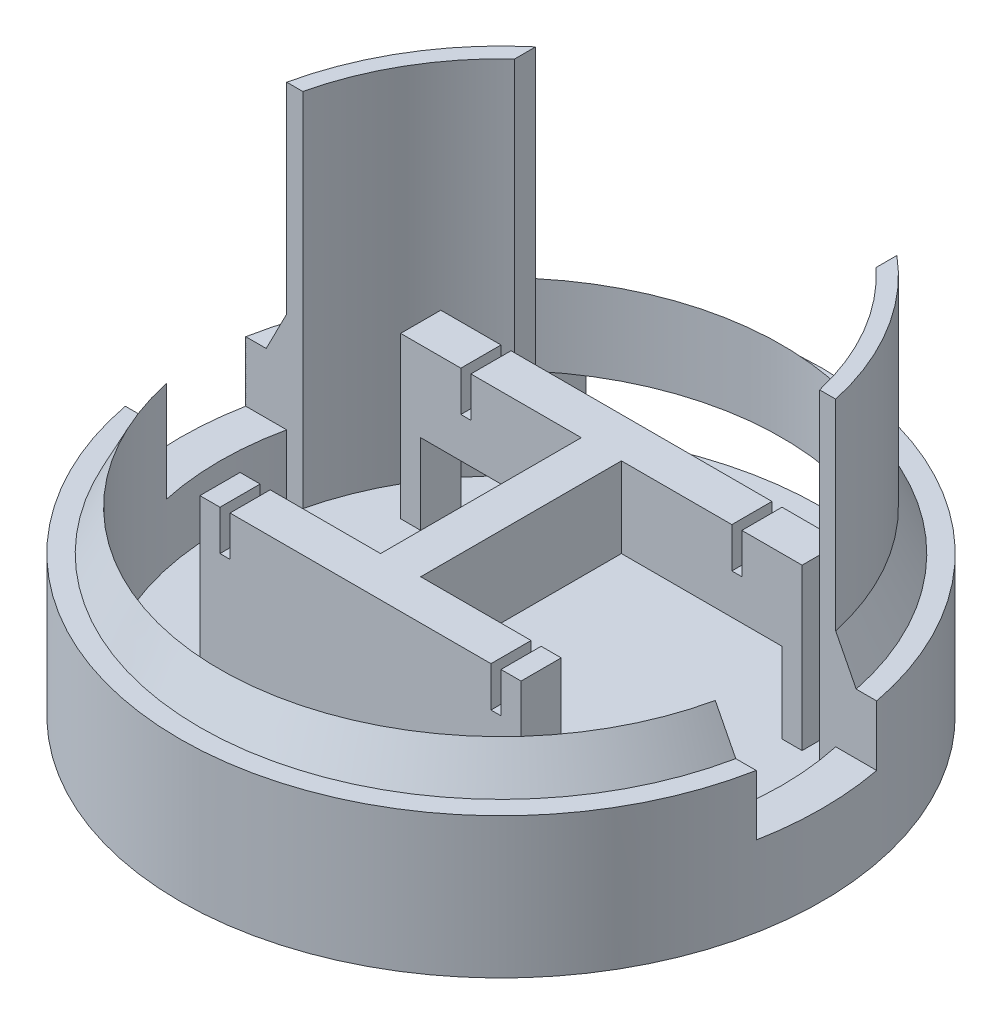
from build123d import *

# Parameters (mm, degrees)
SKETCH1_R               = 50.8
BOSS_EXTRUDE1_DEPTH     = 3.175
SKETCH2_R               = 50.8
SKETCH2_R_2             = 44.45
BOSS_EXTRUDE2_DEPTH     = 19.05
SKETCH5_W               = 50.8
SKETCH5_H               = 6.35
BOSS_EXTRUDE3_DEPTH     = 25.4
SKETCH6_W               = 1.5875
SKETCH6_H               = 6.35
CUT_EXTRUDE1_DEPTH      = 6.35
SKETCH7_W               = 19.05
SKETCH7_H               = 25.4
CUT_EXTRUDE2_DEPTH      = 51.8
CUT_EXTRUDE2_DEPTH_BACK = 51.8
SKETCH8_W               = 57.15
SKETCH8_H               = 12.7
CUT_EXTRUDE3_DEPTH      = 51.8
BOSS_EXTRUDE4_DEPTH     = 57.15
SKETCH10_W              = 6.35
SKETCH10_H              = 3.175
BOSS_EXTRUDE5_DEPTH     = 3.175
SKETCH11_W              = 3.175
SKETCH11_H              = 6.35
BOSS_EXTRUDE6_DEPTH     = 12.7
SKETCH12_W              = 63.5
SKETCH12_H              = 6.35
BOSS_EXTRUDE7_DEPTH     = 12.7
SKETCH14_W              = 6.35
SKETCH14_H              = 12.7
BOSS_EXTRUDE8_DEPTH     = 31.75
BOSS_EXTRUDE9_DEPTH     = 9.525


with BuildPart() as part:
    # Sketch1 → Boss-Extrude1 (new body)
    with BuildSketch(Plane(origin=(0, 0, 0), x_dir=(1, 0, 0), z_dir=(0, 1, 0))):
        with Locations(Location((0, 0, 0), (0, 0, 270))):  # turned: the seam where the file's is
            Circle(SKETCH1_R)
    extrude(amount=-BOSS_EXTRUDE1_DEPTH)

    # Sketch2 → Boss-Extrude2 (add)
    with BuildSketch(Plane(origin=(0, 0, 0), x_dir=(1, 0, 0), z_dir=(0, 1, 0))):
        with Locations(Location((0, 0, 0), (0, 0, 270))):  # turned: the seam where the file's is
            Circle(SKETCH2_R)
        with Locations(Location((0, 0, 0), (0, 0, 270))):  # turned: the seam where the file's is
            Circle(SKETCH2_R_2, mode=Mode.SUBTRACT)
    extrude(amount=BOSS_EXTRUDE2_DEPTH)

    # Sketch3 → Revolve3 (revolve)
    with BuildSketch(Plane.XY, mode=Mode.PRIVATE) as revolve3_sk:
        Polygon((44.45, 19.05), (44.45, 25.4), (47.625, 19.05), align=None)
    revolve(revolve3_sk.sketch.rotate(Axis((0, 6.35, 0), (0, -1, 0)), 90), axis=Axis((0, 6.35, 0), (0, -1, 0)))  # turned: the seam where the file's is

    # Sketch5 → Boss-Extrude3 (add)
    with BuildSketch(Plane(origin=(0, 0, 0), x_dir=(1, 0, 0), z_dir=(0, 1, 0))):
        with Locations((0, -19.05)):
            Rectangle(SKETCH5_W, SKETCH5_H)
    extrude(amount=BOSS_EXTRUDE3_DEPTH)

    # Sketch6 → Cut-Extrude1 (cut)
    with BuildSketch(Plane(origin=(0, 25.4, 0), x_dir=(1, 0, 0), z_dir=(0, 1, 0))):
        with Locations((-21.43125, -19.05)):
            Rectangle(SKETCH6_W, SKETCH6_H)
        with Locations((21.43125, -19.05)):
            Rectangle(SKETCH6_W, SKETCH6_H)
    cut_extrude1 = extrude(amount=-CUT_EXTRUDE1_DEPTH, mode=Mode.SUBTRACT)

    # Sketch7 → Cut-Extrude2 (cut, two sides)
    with BuildSketch(Plane(origin=(0, 0, 0), x_dir=(0, 0, -1), z_dir=(1, 0, 0))) as cut_extrude2_sk:
        with Locations((0, 12.7)):
            Rectangle(SKETCH7_W, SKETCH7_H)
    extrude(amount=CUT_EXTRUDE2_DEPTH, mode=Mode.SUBTRACT)
    extrude(cut_extrude2_sk.sketch, amount=-CUT_EXTRUDE2_DEPTH_BACK, mode=Mode.SUBTRACT)

    # Sketch8 → Cut-Extrude3 (cut, through all)
    with BuildSketch(Plane.XY):
        with Locations((0, 6.35)):
            Rectangle(SKETCH8_W, SKETCH8_H)
    extrude(amount=-CUT_EXTRUDE3_DEPTH, mode=Mode.SUBTRACT)

    # Sketch9 → Boss-Extrude4 (add)
    with BuildSketch(Plane(origin=(0, 0, 0), x_dir=(1, 0, 0), z_dir=(0, 1, 0))):
        with BuildLine():
            Line((-28.575, 34.048081811), (-28.575, 30.74349878))
            ThreePointArc((-28.575, 30.74349878), (-36.310709707, 21.05292623), (-40.877472001, 9.525))
            Line((-40.877472001, 9.525), (-43.417472001, 9.525))
            ThreePointArc((-43.417472001, 9.525), (-38.027284831, 23.015823001), (-28.575, 34.048081811))
        make_face()
        with BuildLine():
            Line((28.575, 34.048081811), (28.575, 30.74349878))
            ThreePointArc((28.575, 30.74349878), (36.310709707, 21.05292623), (40.877472001, 9.525))
            Line((40.877472001, 9.525), (43.417472001, 9.525))
            ThreePointArc((43.417472001, 9.525), (38.027284831, 23.015823001), (28.575, 34.048081811))
        make_face()
    extrude(amount=BOSS_EXTRUDE4_DEPTH)

    # Sketch10 → Boss-Extrude5 (add)
    with BuildSketch(Plane(origin=(0, 0, 15.875), x_dir=(-1, 0, 0), z_dir=(0, 0, -1))):
        with Locations((0, 11.1125)):
            Rectangle(SKETCH10_W, SKETCH10_H)
    extrude(amount=BOSS_EXTRUDE5_DEPTH)

    # Sketch11 → Boss-Extrude6 (add)
    with BuildSketch(Plane(origin=(0, 0, 0), x_dir=(1, 0, 0), z_dir=(0, 1, 0))):
        with Locations((-30.1625, 19.05)):
            Rectangle(SKETCH11_W, SKETCH11_H)
        with Locations((30.1625, 19.05)):
            Rectangle(SKETCH11_W, SKETCH11_H)
    extrude(amount=BOSS_EXTRUDE6_DEPTH)

    # Sketch12 → Boss-Extrude7 (add)
    with BuildSketch(Plane(origin=(0, 12.7, 0), x_dir=(1, 0, 0), z_dir=(0, 1, 0))):
        with Locations((0, 19.05)):
            Rectangle(SKETCH12_W, SKETCH12_H)
    extrude(amount=BOSS_EXTRUDE7_DEPTH)

    # Mirror1: Cut-Extrude1 across plane
    add(cut_extrude1.mirror(Plane.XY), mode=Mode.SUBTRACT)

    # Sketch14 → Boss-Extrude8 (add)
    with BuildSketch(Plane.XY.offset(-15.875)):
        with Locations((0, 19.05)):
            Rectangle(SKETCH14_W, SKETCH14_H)
    extrude(amount=BOSS_EXTRUDE8_DEPTH)

    # Sketch15 → Boss-Extrude9 (add)
    with BuildSketch(Plane(origin=(0, 0, 0), x_dir=(1, 0, 0), z_dir=(0, 1, 0))):
        with BuildLine():
            Line((-49.899041824, 9.525), (-43.417472001, 9.525))
            ThreePointArc((-43.417472001, 9.525), (-44.45, 0), (-43.417472001, -9.525))
            Line((-43.417472001, -9.525), (-49.899041824, -9.525))
            ThreePointArc((-49.899041824, -9.525), (-50.8, 0), (-49.899041824, 9.525))
        make_face()
        with BuildLine():
            Line((43.417472001, 9.525), (49.899041824, 9.525))
            ThreePointArc((49.899041824, 9.525), (50.8, 0), (49.899041824, -9.525))
            Line((49.899041824, -9.525), (43.417472001, -9.525))
            ThreePointArc((43.417472001, -9.525), (44.45, 0), (43.417472001, 9.525))
        make_face()
    extrude(amount=BOSS_EXTRUDE9_DEPTH)


solid = part.part
